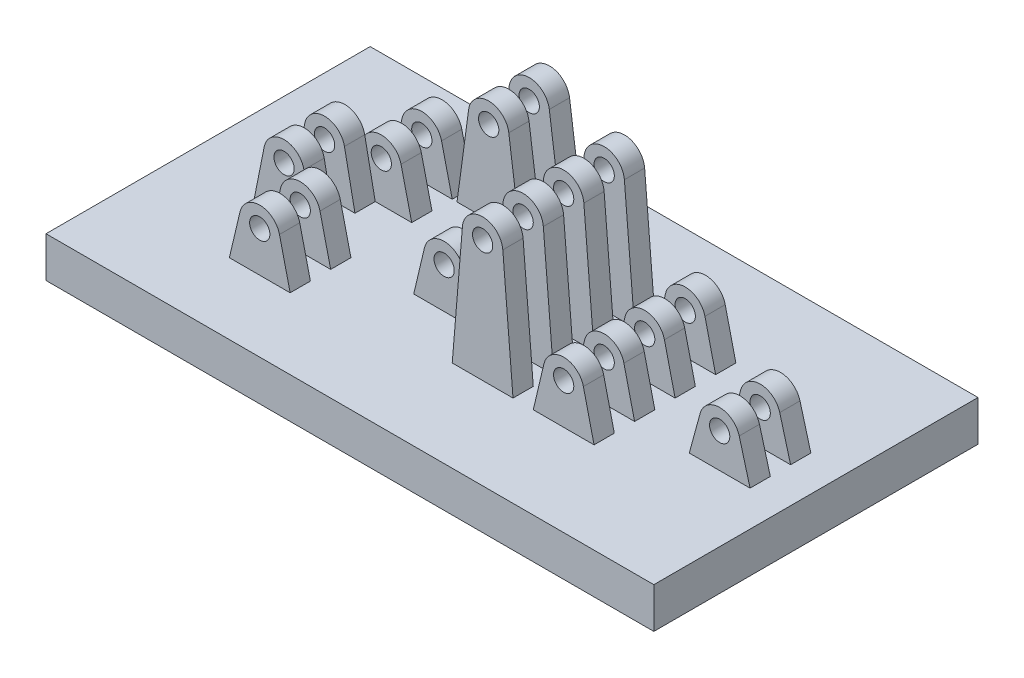
from build123d import *

# Parameters (mm, degrees)
EXTRUDE_START       = -10
SKETCH_3_W          = 150
SKETCH_3_H          = 80
EXTRUDE_3_DEPTH     = 10
SKETCH_5_R          = 2.5
EXTRUDE_5_DEPTH     = 22.5
SKETCH_6_W          = 53.56449621
SKETCH_6_H          = 15
SKETCH_6_W_2        = 55.316324433
SKETCH_6_H_2        = 5
SKETCH_6_W_3        = 50.048103058
CUT_EXTRUDE_1_DEPTH = 40
SKETCH_7_R          = 2.5
EXTRUDE_6_DEPTH     = 17.5
SKETCH_4_R          = 2.5
EXTRUDE_4_DEPTH     = 7.5
EXTRUDE_START_2     = -17.5
SKETCH_9_R          = 2.5
EXTRUDE_7_DEPTH     = 15
SKETCH_8_W          = 149.834413798
SKETCH_8_H          = 5
SKETCH_8_W_2        = 53.466456482
SKETCH_8_W_3        = 46.484368984
SKETCH_8_W_4        = 21.970588524
CUT_EXTRUDE_2_DEPTH = 35


with BuildPart() as part:
    # 草圖3 → 填料-伸長3 (new body)
    with BuildSketch(Plane(origin=(0, 0, 0), x_dir=(1, 0, 0), z_dir=(0, 1, 0)).offset(EXTRUDE_START)):
        with Locations((33.25, 0)):
            Rectangle(SKETCH_3_W, SKETCH_3_H)
    extrude(amount=-EXTRUDE_3_DEPTH)

    # 草圖5 → 填料-伸長5 (add, symmetric)
    with BuildSketch(Plane.XY):
        with BuildLine():
            Line((-11.366060556, 1.149545417), (-14, -10))
            Line((-14, -10), (1, -10))
            Line((1, -10), (-1.633939444, 1.149545417))
            ThreePointArc((-1.633939444, 1.149545417), (-6.5, 5), (-11.366060556, 1.149545417))
        make_face()
        with Locations((-6.5, 0)):
            Circle(SKETCH_5_R, mode=Mode.SUBTRACT)
    extrude(amount=EXTRUDE_5_DEPTH, both=True)

    # 草圖6 → 除料-伸長1 (cut)
    with BuildSketch(Plane(origin=(0, -10, 0), x_dir=(1, 0, 0), z_dir=(0, 1, 0))):
        with Locations((-2.489143795, 0)):
            Rectangle(SKETCH_6_W, SKETCH_6_H)
        with Locations((-4.247340371, -15)):
            Rectangle(SKETCH_6_W_2, SKETCH_6_H_2)
        with Locations((-1.613229684, 15)):
            Rectangle(SKETCH_6_W_3, SKETCH_6_H_2)
    extrude(amount=CUT_EXTRUDE_1_DEPTH, mode=Mode.SUBTRACT)

    # 草圖7 → 填料-伸長6 (add, symmetric)
    with BuildSketch(Plane.XY):
        with BuildLine():
            Line((58.633939444, 1.149545417), (56, -10))
            Line((56, -10), (71, -10))
            Line((71, -10), (68.366060556, 1.149545417))
            ThreePointArc((68.366060556, 1.149545417), (63.5, 5), (58.633939444, 1.149545417))
        make_face()
        with Locations((63.5, 0)):
            Circle(SKETCH_7_R, mode=Mode.SUBTRACT)
        with BuildLine():
            Line((38.517037013, 20.412407413), (36, -10))
            Line((36, -10), (51, -10))
            Line((51, -10), (48.482962987, 20.412407413))
            ThreePointArc((48.482962987, 20.412407413), (43.5, 25), (38.517037013, 20.412407413))
        make_face()
        with Locations((43.5, 20)):
            Circle(SKETCH_7_R, mode=Mode.SUBTRACT)
    extrude(amount=EXTRUDE_6_DEPTH, both=True)

    # 草圖4 → 填料-伸長4 (add, symmetric)
    with BuildSketch(Plane.XY):
        with BuildLine():
            Line((87.176081429, -0.184777731), (84.5, -10))
            Line((84.5, -10), (99.5, -10))
            Line((99.5, -10), (96.823918571, -0.184777731))
            ThreePointArc((96.823918571, -0.184777731), (92, 3.5), (87.176081429, -0.184777731))
        make_face()
        with Locations((92, -1.5)):
            Circle(SKETCH_4_R, mode=Mode.SUBTRACT)
        with BuildLine():
            Line((-20.402832148, 2.980936759), (-23, -10))
            Line((-23, -10), (-8, -10))
            Line((-8, -10), (-10.597167852, 2.980936759))
            ThreePointArc((-10.597167852, 2.980936759), (-15.5, 7), (-20.402832148, 2.980936759))
        make_face()
        with Locations((-15.5, 2)):
            Circle(SKETCH_4_R, mode=Mode.SUBTRACT)
        with BuildLine():
            Line((19.133939444, 1.149545417), (16.5, -10))
            Line((16.5, -10), (31.5, -10))
            Line((31.5, -10), (28.866060556, 1.149545417))
            ThreePointArc((28.866060556, 1.149545417), (24, 5), (19.133939444, 1.149545417))
        make_face()
        with Locations((24, 0)):
            Circle(SKETCH_4_R, mode=Mode.SUBTRACT)
    extrude(amount=EXTRUDE_4_DEPTH, both=True)

    # 草圖9 → 填料-伸長7 (add)
    with BuildSketch(Plane.XY.offset(EXTRUDE_START_2)):
        with BuildLine():
            Line((5.045078047, 11.169886883), (2.182988659, -10))
            Line((2.182988659, -10), (17.817011341, -10))
            Line((17.817011341, -10), (14.954921953, 11.169886883))
            ThreePointArc((14.954921953, 11.169886883), (10, 15.5), (5.045078047, 11.169886883))
        make_face()
        with Locations((10, 10.5)):
            Circle(SKETCH_9_R, mode=Mode.SUBTRACT)
    extrude(amount=-EXTRUDE_7_DEPTH)

    # 草圖8 → 除料-伸長2 (cut)
    with BuildSketch(Plane(origin=(0, -10, 0), x_dir=(1, 0, 0), z_dir=(0, 1, 0))):
        with Locations((38.363273687, 0)):
            Rectangle(SKETCH_8_W, SKETCH_8_H)
        with Locations((60.98088391, 10)):
            Rectangle(SKETCH_8_W_2, SKETCH_8_H)
        with Locations((56.879490972, -10)):
            Rectangle(SKETCH_8_W_3, SKETCH_8_H)
        with Locations((12.54422866, 25)):
            Rectangle(SKETCH_8_W_4, SKETCH_8_H)
    extrude(amount=CUT_EXTRUDE_2_DEPTH, mode=Mode.SUBTRACT)


solid = part.part
